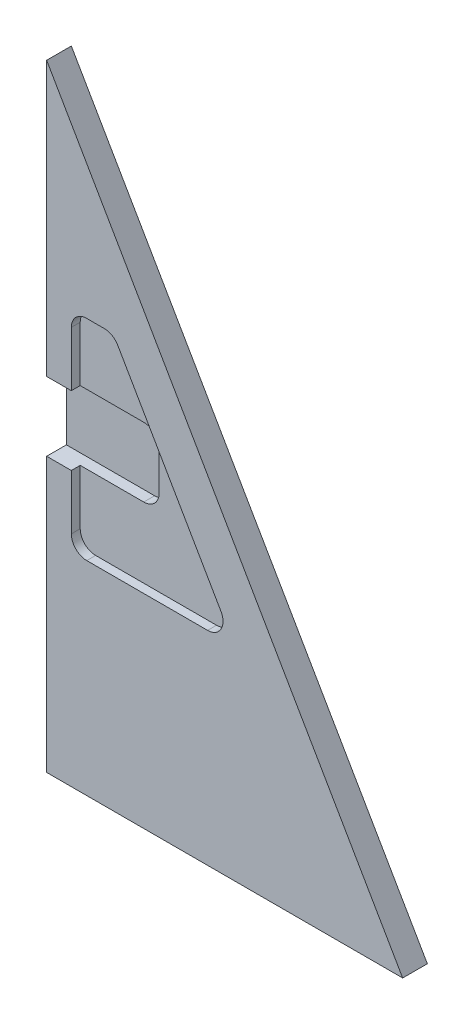
from build123d import *

# Parameters (mm, degrees)
EXTRUDE1_DEPTH = 2.54
EXTRUDE3_DEPTH = 2.032
EXTRUDE2_DEPTH = 0.9144
FILLET1_R      = 1.5875


with BuildPart() as part:
    # Sketch1 → Extrude1 (new body)
    with BuildSketch(Plane.XY):
        Polygon((0, 63.5), (36.6522, 0), (0, 0), align=None)
    extrude(amount=-EXTRUDE1_DEPTH)

    # Sketch4 → Extrude3 (cut)
    with BuildSketch(Plane.XY):
        Polygon((0, 31.75), (0, 35.306), (10.668, 35.306), (10.668, 28.194), (0, 28.194), align=None)
    extrude(amount=-EXTRUDE3_DEPTH, mode=Mode.SUBTRACT)

    # Sketch3 → Extrude2 (cut)
    with BuildSketch(Plane.XY):
        Polygon((2.54, 31.75), (2.54, 42.545), (6.858, 42.545), (19.319748, 20.955), (2.54, 20.955), align=None)
    extrude(amount=-EXTRUDE2_DEPTH, mode=Mode.SUBTRACT)

    # Fillet1
    fillet1_edges = [part.edges().sort_by_distance(p)[0] for p in [
        (10.668, 35.306, -1.4732),
        (10.668, 28.194, -1.4732),
        (2.54, 20.955, -0.4572),
        (2.54, 42.545, -0.4572),
        (6.858, 42.545, -0.4572),
        (19.319748, 20.955, -0.4572),
    ]]
    fillet(fillet1_edges, radius=FILLET1_R)


solid = part.part
